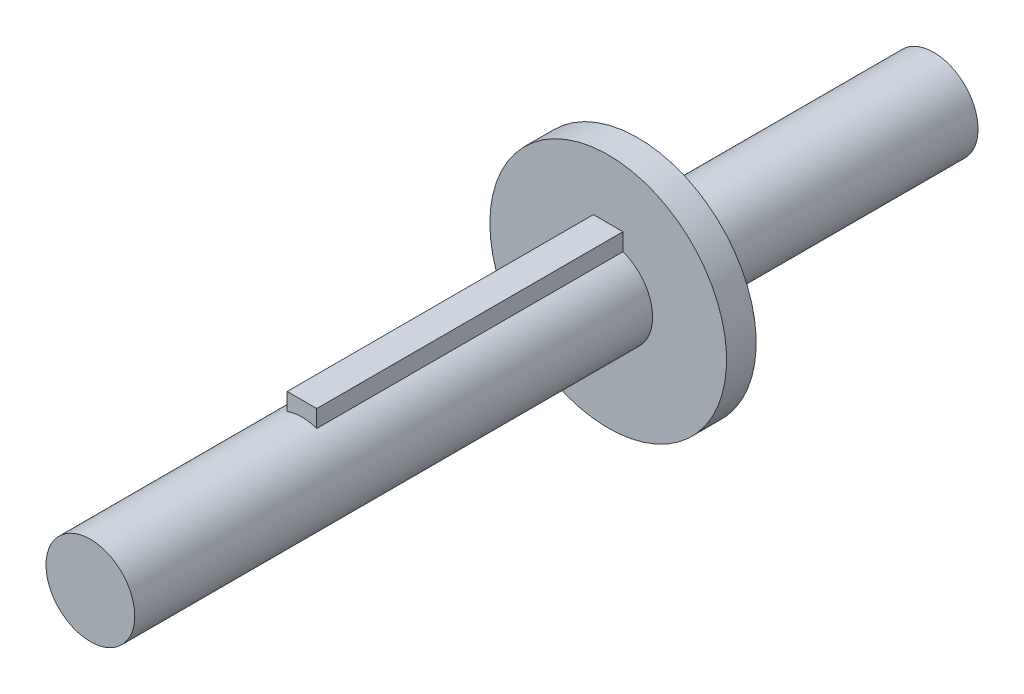
from build123d import *

# Parameters (mm, degrees)
SKETCH1_R           = 3
BOSS_EXTRUDE1_DEPTH = 35
SKETCH3_R           = 8
BOSS_EXTRUDE3_DEPTH = 2
SKETCH2_W           = 2
SKETCH2_H           = 1.17
BOSS_EXTRUDE4_DEPTH = 20.7
SKETCH4_R           = 3
BOSS_EXTRUDE5_DEPTH = 20


with BuildPart() as part:
    # Sketch1 → Boss-Extrude1 (new body)
    with BuildSketch(Plane.XY):
        Circle(SKETCH1_R)
    extrude(amount=BOSS_EXTRUDE1_DEPTH)

    # Sketch3 → Boss-Extrude3 (add)
    with BuildSketch(Plane(origin=(0, 0, 0), x_dir=(-1, 0, 0), z_dir=(0, 0, -1))):
        Circle(SKETCH3_R)
    extrude(amount=BOSS_EXTRUDE3_DEPTH)

    # Sketch2 → Boss-Extrude4 (add)
    with BuildSketch(Plane(origin=(0, 0, 0), x_dir=(-1, 0, 0), z_dir=(0, 0, -1))):
        with Locations((0, 3.413427125)):
            Rectangle(SKETCH2_W, SKETCH2_H)
    extrude(amount=-BOSS_EXTRUDE4_DEPTH)

    # Sketch4 → Boss-Extrude5 (add)
    with BuildSketch(Plane(origin=(0, 0, -2), x_dir=(-1, 0, 0), z_dir=(0, 0, -1))):
        Circle(SKETCH4_R)
    extrude(amount=BOSS_EXTRUDE5_DEPTH)


solid = part.part
